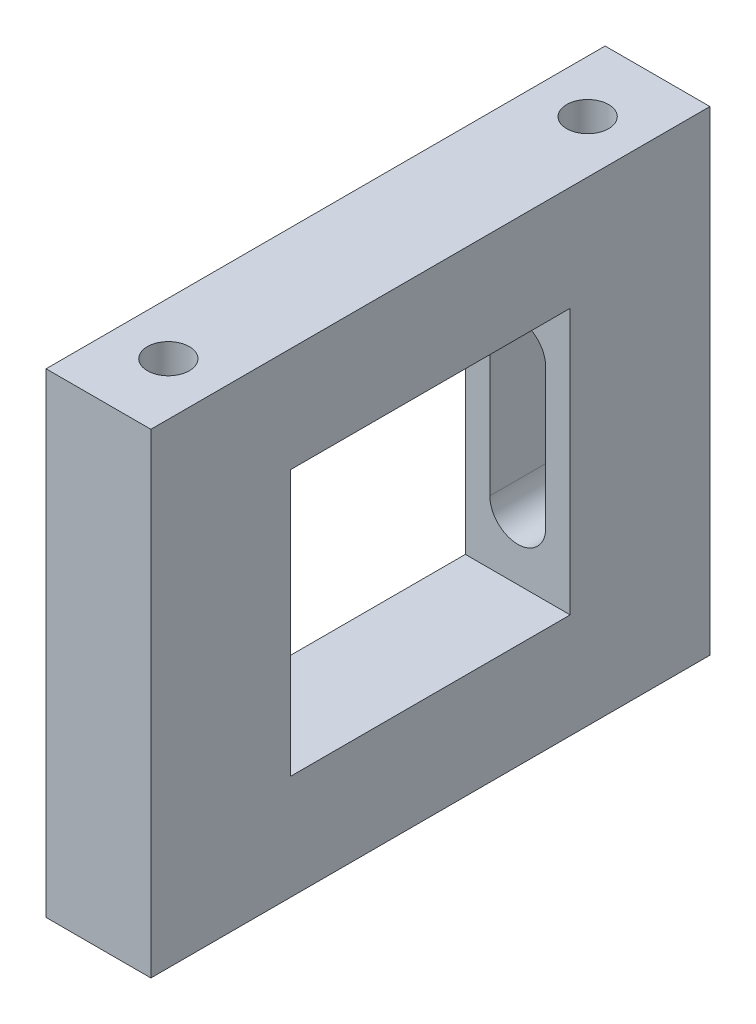
from build123d import *

# Parameters (mm, degrees)
ESBO_O1_W                = 15
ESBO_O1_H                = 15
RESSALTO_EXTRUS_O1_DEPTH = 80
ESBO_O2_W                = 15
ESBO_O2_H                = 20
RESSALTO_EXTRUS_O2_DEPTH = 53
CORTE_EXTRUS_O1_DEPTH    = 21
ESBO_O5_R                = 3
CORTE_EXTRUS_O2_DEPTH    = 16.5
ESBO_O6_W                = 15
ESBO_O6_H                = 15
RESSALTO_EXTRUS_O3_DEPTH = 40


with BuildPart() as part:
    # Esboço1 → Ressalto-extrusão1 (new body)
    with BuildSketch(Plane.XY):
        with Locations((-60, 0)):
            Rectangle(ESBO_O1_W, ESBO_O1_H)
    extrude(amount=RESSALTO_EXTRUS_O1_DEPTH)

    # Esboço2 → Ressalto-extrusão2 (add)
    with BuildSketch(Plane(origin=(0, 7.5, 0), x_dir=(1, 0, 0), z_dir=(0, 1, 0))):
        with Locations((-60, -10)):
            Rectangle(ESBO_O2_W, ESBO_O2_H)
        with Locations((-60, -70)):
            Rectangle(ESBO_O2_W, ESBO_O2_H)
    extrude(amount=RESSALTO_EXTRUS_O2_DEPTH)

    # Esboço4 → Corte-extrusão1 (cut, through all)
    with BuildSketch(Plane.XY.offset(20)):
        with BuildLine():
            Line((-56, 36.5), (-56, 16.5))
            ThreePointArc((-56, 16.5), (-60, 12.5), (-64, 16.5))
            Line((-64, 16.5), (-64, 36.5))
            ThreePointArc((-64, 36.5), (-60, 40.5), (-56, 36.5))
        make_face()
    extrude(amount=-CORTE_EXTRUS_O1_DEPTH, mode=Mode.SUBTRACT)

    # Esboço5 → Corte-extrusão2 (cut)
    with BuildSketch(Plane(origin=(0, 60.5, 0), x_dir=(1, 0, 0), z_dir=(0, 1, 0))):
        with Locations((-60, -10)):
            Circle(ESBO_O5_R)
        with Locations((-60, -70)):
            Circle(ESBO_O5_R)
    extrude(amount=-CORTE_EXTRUS_O2_DEPTH, mode=Mode.SUBTRACT)

    # Esboço6 → Ressalto-extrusão3 (add)
    with BuildSketch(Plane.XY.offset(20)):
        with Locations((-60, 53)):
            Rectangle(ESBO_O6_W, ESBO_O6_H)
    extrude(amount=RESSALTO_EXTRUS_O3_DEPTH)


solid = part.part
